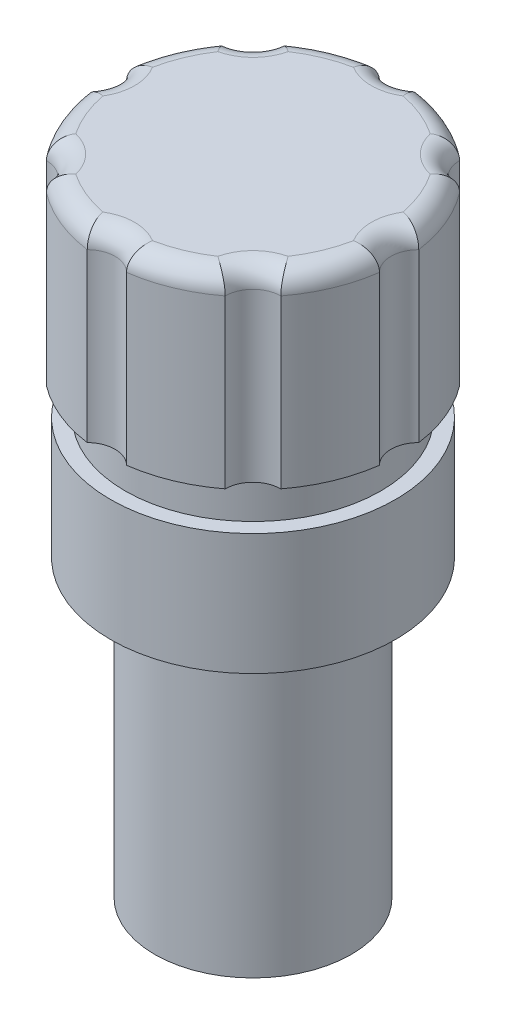
from build123d import *

# Parameters (mm, degrees)
SKETCH1_R           = 10
BOSS_EXTRUDE1_DEPTH = 30
SKETCH2_R           = 14.5
BOSS_EXTRUDE2_DEPTH = 12.34
SKETCH3_R           = 13
BOSS_EXTRUDE3_DEPTH = 4.2
SKETCH4_R           = 15
BOSS_EXTRUDE4_DEPTH = 19
CUT_EXTRUDE1_DEPTH  = 19
FILLET2_R           = 2


with BuildPart() as part:
    # Sketch1 → Boss-Extrude1 (new body)
    with BuildSketch(Plane(origin=(0, 0, 0), x_dir=(1, 0, 0), z_dir=(0, 1, 0))):
        Circle(SKETCH1_R)
    extrude(amount=BOSS_EXTRUDE1_DEPTH)

    # Sketch2 → Boss-Extrude2 (add)
    with BuildSketch(Plane(origin=(0, 30, 0), x_dir=(1, 0, 0), z_dir=(0, 1, 0))):
        Circle(SKETCH2_R)
    extrude(amount=BOSS_EXTRUDE2_DEPTH)

    # Sketch3 → Boss-Extrude3 (add)
    with BuildSketch(Plane(origin=(0, 42.34, 0), x_dir=(1, 0, 0), z_dir=(0, 1, 0))):
        Circle(SKETCH3_R)
    extrude(amount=BOSS_EXTRUDE3_DEPTH)

    # Sketch4 → Boss-Extrude4 (add)
    with BuildSketch(Plane(origin=(0, 46.54, 0), x_dir=(1, 0, 0), z_dir=(0, 1, 0))):
        Circle(SKETCH4_R)
    extrude(amount=BOSS_EXTRUDE4_DEPTH)

    # Sketch5 → Cut-Extrude1 (cut)
    with BuildSketch(Plane(origin=(0, 65.54, 0), x_dir=(1, 0, 0), z_dir=(0, 1, 0))):
        with BuildLine():
            ThreePointArc((-14.866053103, 2.000116283), (-15, 5.8666e-05), (-14.866068747, -2))
            ThreePointArc((-14.866068747, -2), (-14.037575657, 5.4901e-05), (-14.866053103, 2.000116283))
        make_face()
        with BuildLine():
            ThreePointArc((-2, 14.866068747), (5.4901e-05, 14.037575657), (2.000116283, 14.866053103))
            ThreePointArc((2.000116283, 14.866053103), (5.8666e-05, 15), (-2, 14.866068747))
        make_face()
        with BuildLine():
            ThreePointArc((9.097684458, 11.926111583), (9.92610376, 9.926026117), (11.926182746, 9.097591171))
            ThreePointArc((11.926182746, 9.097591171), (10.606643201, 10.606560235), (9.097684458, 11.926111583))
        make_face()
        with BuildLine():
            ThreePointArc((14.866068747, 2), (14.037575657, -5.4901e-05), (14.866053103, -2.000116283))
            ThreePointArc((14.866053103, -2.000116283), (15, -5.8666e-05), (14.866068747, 2))
        make_face()
        with BuildLine():
            ThreePointArc((11.926111583, -9.097684458), (9.926026117, -9.92610376), (9.097591171, -11.926182746))
            ThreePointArc((9.097591171, -11.926182746), (10.606560235, -10.606643201), (11.926111583, -9.097684458))
        make_face()
        with BuildLine():
            ThreePointArc((2, -14.866068747), (-5.4901e-05, -14.037575657), (-2.000116283, -14.866053103))
            ThreePointArc((-2.000116283, -14.866053103), (-5.8666e-05, -15), (2, -14.866068747))
        make_face()
        with BuildLine():
            ThreePointArc((-9.097684458, -11.926111583), (-9.92610376, -9.926026117), (-11.926182746, -9.097591171))
            ThreePointArc((-11.926182746, -9.097591171), (-10.606643201, -10.606560235), (-9.097684458, -11.926111583))
        make_face()
        with BuildLine():
            ThreePointArc((-11.926111583, 9.097684458), (-9.926026117, 9.92610376), (-9.097591171, 11.926182746))
            ThreePointArc((-9.097591171, 11.926182746), (-10.606560235, 10.606643201), (-11.926111583, 9.097684458))
        make_face()
    extrude(amount=-CUT_EXTRUDE1_DEPTH, mode=Mode.SUBTRACT)

    # Fillet2
    fillet2_edges = [part.edges().sort_by_distance(p)[0] for p in [
        (-5.740197286, 65.54, -13.858215438),
        (5.4901e-05, 65.54, -14.037575657),
        (5.740305685, 65.54, -13.858170537),
        (9.92610376, 65.54, -9.926026117),
        (13.858215438, 65.54, -5.740197286),
        (14.037575657, 65.54, 5.4901e-05),
        (13.858170537, 65.54, 5.740305685),
        (9.926026117, 65.54, 9.92610376),
        (5.740197286, 65.54, 13.858215438),
        (-5.4901e-05, 65.54, 14.037575657),
        (-5.740305685, 65.54, 13.858170537),
        (-9.92610376, 65.54, 9.926026117),
        (-13.858215438, 65.54, 5.740197286),
        (-14.037575657, 65.54, -5.4901e-05),
        (-13.858170537, 65.54, -5.740305685),
        (-9.926026117, 65.54, -9.92610376),
    ]]
    fillet(fillet2_edges, radius=FILLET2_R)


solid = part.part
